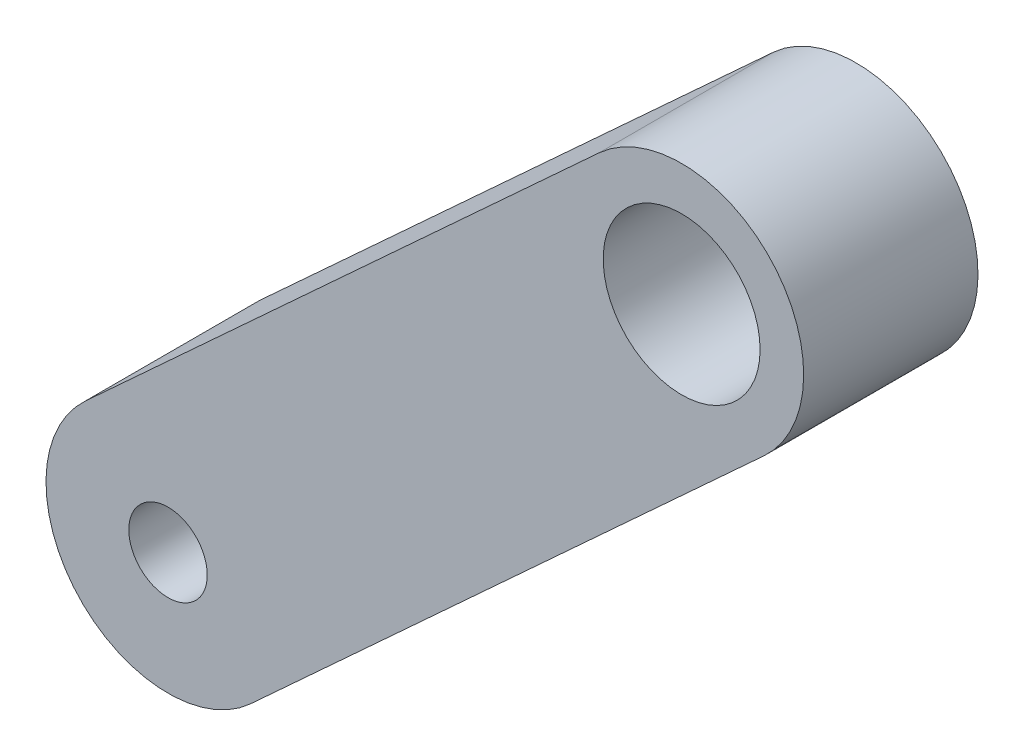
from build123d import *

# Parameters (mm, degrees)
SKETCH1_R           = 22.5
SKETCH1_R_2         = 45
BOSS_EXTRUDE1_DEPTH = 100


with BuildPart() as part:
    # Sketch1 → Boss-Extrude1 (new body)
    with BuildSketch(Plane.XY):
        with BuildLine():
            Line((-47.347064855, 51.558272368), (247.271634392, 322.112928684))
            ThreePointArc((247.271634392, 322.112928684), (346.176971615, 317.901721171), (341.965764102, 218.996383947))
            Line((341.965764102, 218.996383947), (47.347064855, -51.558272368))
            ThreePointArc((47.347064855, -51.558272368), (-51.558272368, -47.347064855), (-47.347064855, 51.558272368))
        make_face()
        Circle(SKETCH1_R, mode=Mode.SUBTRACT)
        with Locations((294.618699247, 270.554656316)):
            Circle(SKETCH1_R_2, mode=Mode.SUBTRACT)
    extrude(amount=BOSS_EXTRUDE1_DEPTH)


solid = part.part
